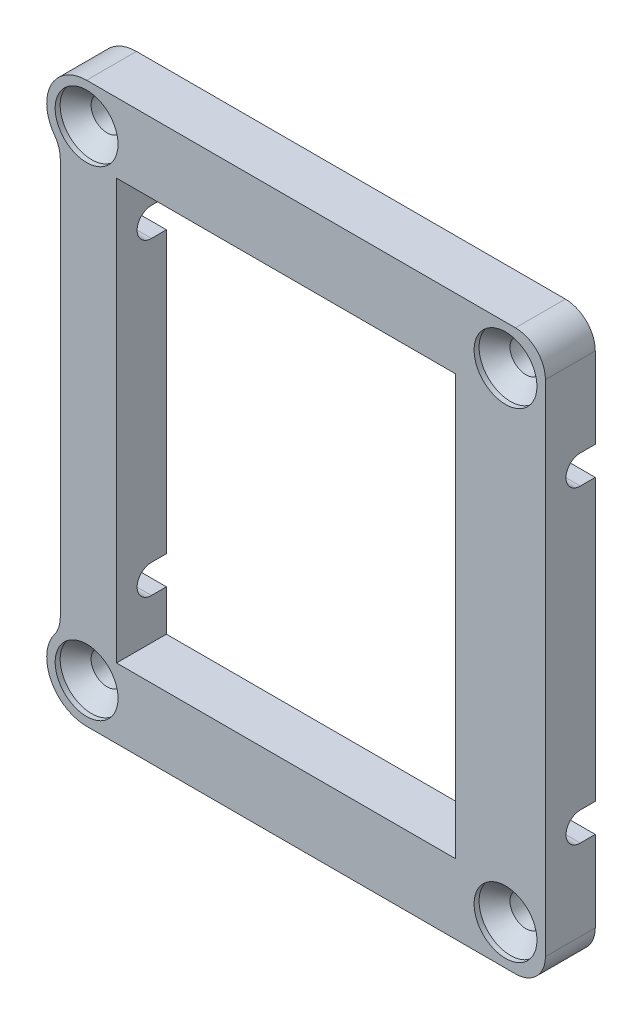
from build123d import *

# Parameters (mm, degrees)
SKETCH1_R                                    = 1.25
SKETCH1_W                                    = 36
SKETCH1_H                                    = 42.1
BOSS_EXTRUDE1_DEPTH                          = 5
SKETCH6_W                                    = 2
SKETCH6_H                                    = 42.1
BOSS_EXTRUDE4_DEPTH                          = 5
CSK_FOR_M3_COUNTERSUNK_FLAT_HEAD_SCR_2_COUNT = 2
CSK_FOR_M3_COUNTERSUNK_FLAT_HEAD_SCR_2_PITCH = 48.1
CSK_FOR_M3_COUNTERSUNK_FLAT_HEAD_SCR_3_COUNT = 2
CSK_FOR_M3_COUNTERSUNK_FLAT_HEAD_SCR_3_PITCH = 63.856166499
CSK_FOR_M3_COUNTERSUNK_FLAT_HEAD_SCR_4_COUNT = 2
CSK_FOR_M3_COUNTERSUNK_FLAT_HEAD_SCR_4_PITCH = 42
FURO_COM_FOLGA_DE_M34_D                      = 2.87
FILETE1_R                                    = 3
ESBO_O3_W                                    = 1.5
ESBO_O3_H                                    = 2.87
CORTE_EXTRUS_O1_DEPTH                        = 63
CORTE_EXTRUS_O1_DEPTH_BACK                   = 10


with BuildPart() as part:
    # Sketch1 → Boss-Extrude1 (new body)
    with BuildSketch(Plane.XY):
        with BuildLine():
            Line((20.053938932, -66.638943184), (63.053938932, -66.638943184))
            ThreePointArc((63.053938932, -66.638943184), (65.175259276, -67.517622841), (66.053938932, -69.638943184))
            Line((66.053938932, -69.638943184), (66.053938932, -119.738943184))
            ThreePointArc((66.053938932, -119.738943184), (65.175259276, -121.860263528), (63.053938932, -122.738943184))
            Line((63.053938932, -122.738943184), (20.053938932, -122.738943184))
            ThreePointArc((20.053938932, -122.738943184), (16.310928808, -120.149572552), (17.413938931, -115.73388079))
            Line((17.413938931, -115.73388079), (17.413938931, -73.644005579))
            ThreePointArc((17.413938931, -73.644005579), (16.310928808, -69.228313817), (20.053938932, -66.638943184))
        make_face()
        with Locations((20.053938932, -70.638943184)):
            Circle(SKETCH1_R, mode=Mode.SUBTRACT)
        with Locations((20.053938932, -118.738943184)):
            Circle(SKETCH1_R, mode=Mode.SUBTRACT)
        with Locations((62.053938932, -70.638943184)):
            Circle(SKETCH1_R, mode=Mode.SUBTRACT)
        with Locations((62.053938932, -118.738943184)):
            Circle(SKETCH1_R, mode=Mode.SUBTRACT)
        with Locations((41.053938932, -94.688943184)):
            Rectangle(SKETCH1_W, SKETCH1_H, mode=Mode.SUBTRACT)
    extrude(amount=BOSS_EXTRUDE1_DEPTH)

    # Sketch6 → Boss-Extrude4 (add)
    with BuildSketch(Plane.XY.offset(5)):
        with Locations((58.053938932, -94.688943184)):
            Rectangle(SKETCH6_W, SKETCH6_H)
    extrude(amount=-BOSS_EXTRUDE4_DEPTH)

    # Sketch2 → CSK for M3 Countersunk Flat Head Screw1 (revolve, cut)
    with BuildSketch(Plane(origin=(20.053938932, -118.738943184, 5), x_dir=(0, -1, 0), z_dir=(1, 0, 0))):
        Polygon((0, 0), (0, 5), (1.6, 5), (1.6, 2.05), (3.15, 0.5), (3.15, 0), align=None)
    csk_for_m3_countersunk_flat_head_screw1 = revolve(axis=Axis((20.053938932, -118.738943184, 11.35), (0, 0, -1)), mode=Mode.SUBTRACT)

    # CSK for M3 Countersunk Flat Head Scr 2: CSK for M3 Countersunk Flat Head Screw1 ×2
    with Locations(*[(0, i * CSK_FOR_M3_COUNTERSUNK_FLAT_HEAD_SCR_2_PITCH, 0) for i in range(1, CSK_FOR_M3_COUNTERSUNK_FLAT_HEAD_SCR_2_COUNT)]):
        add(csk_for_m3_countersunk_flat_head_screw1, mode=Mode.SUBTRACT)

    # CSK for M3 Countersunk Flat Head Scr 3: CSK for M3 Countersunk Flat Head Screw1 ×2
    with Locations(*[Vector(0.657728177, 0.753255365, 0) * (i * CSK_FOR_M3_COUNTERSUNK_FLAT_HEAD_SCR_3_PITCH) for i in range(1, CSK_FOR_M3_COUNTERSUNK_FLAT_HEAD_SCR_3_COUNT)]):
        add(csk_for_m3_countersunk_flat_head_screw1, mode=Mode.SUBTRACT)

    # CSK for M3 Countersunk Flat Head Scr 4: CSK for M3 Countersunk Flat Head Screw1 ×2
    with Locations(*[(i * CSK_FOR_M3_COUNTERSUNK_FLAT_HEAD_SCR_4_PITCH, 0, 0) for i in range(1, CSK_FOR_M3_COUNTERSUNK_FLAT_HEAD_SCR_4_COUNT)]):
        add(csk_for_m3_countersunk_flat_head_screw1, mode=Mode.SUBTRACT)

    # Furo com folga de M34 (through all)
    with Locations(Plane(origin=(66.053938932, 0, 0), x_dir=(0, 0, -1), z_dir=(1, 0, 0))):
        with Locations((-1.5, -79.188943184), (-1.5, -110.188943184)):
            Hole(FURO_COM_FOLGA_DE_M34_D / 2)

    # Filete1
    filete1_edges = [part.edges().sort_by_distance(p)[0] for p in [
        (17.413938931, -115.73388079, 2.5),
        (17.413938931, -73.644005579, 2.5),
    ]]
    fillet(filete1_edges, radius=FILETE1_R)

    # Esboço3 → Corte-extrusão1 (cut, two sides)
    with BuildSketch(Plane.ZY.offset(-57.053938932)) as corte_extrus_o1_sk:
        with Locations((0.75, -79.188943184)):
            Rectangle(ESBO_O3_W, ESBO_O3_H)
        with Locations((0.75, -110.188943184)):
            Rectangle(ESBO_O3_W, ESBO_O3_H)
    extrude(amount=CORTE_EXTRUS_O1_DEPTH, mode=Mode.SUBTRACT)
    extrude(corte_extrus_o1_sk.sketch, amount=-CORTE_EXTRUS_O1_DEPTH_BACK, mode=Mode.SUBTRACT)


solid = part.part
